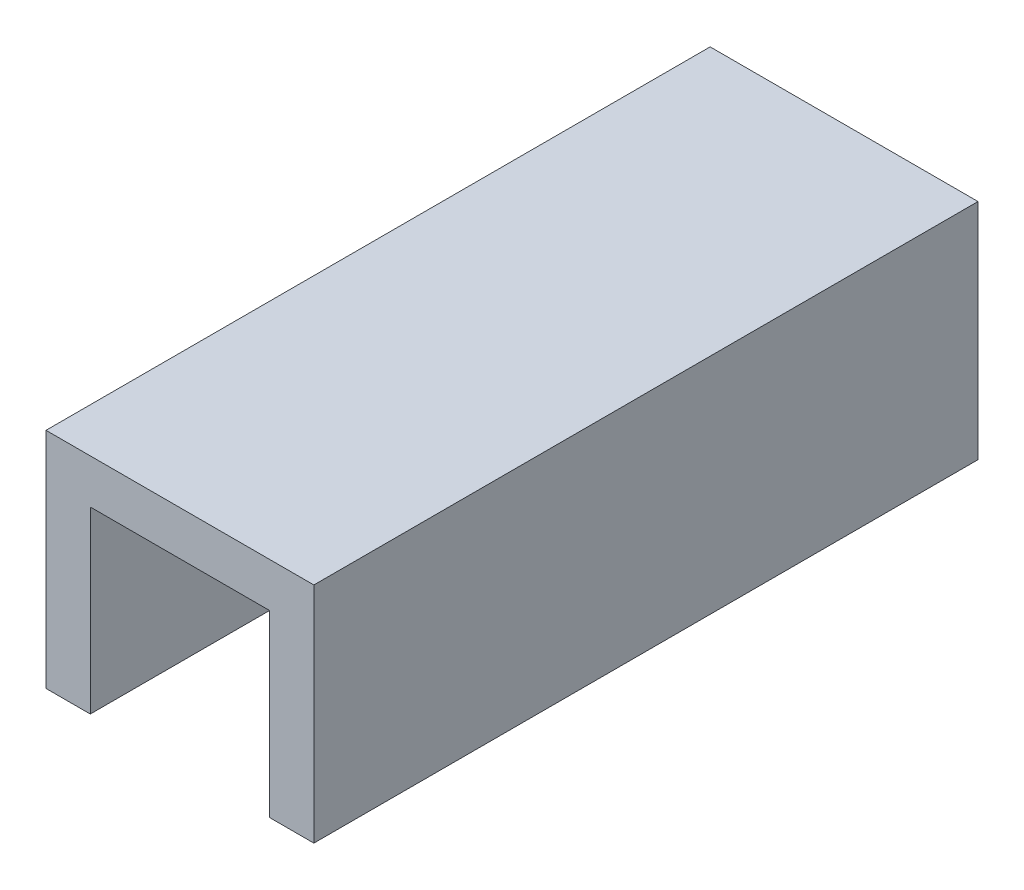
from build123d import *

# Parameters (mm, degrees)
SALIENTE_EXTRUIR1_DEPTH = 300


with BuildPart() as part:
    # Croquis1 → Saliente-Extruir1 (new body)
    with BuildSketch(Plane.XY):
        Polygon((-60.5, -40.5), (-60.5, 60.5), (60.5, 60.5), (60.5, -40.5), (40.5, -40.5), (40.5, 40.5), (-40.5, 40.5), (-40.5, -40.5), align=None)
    extrude(amount=SALIENTE_EXTRUIR1_DEPTH)


solid = part.part
